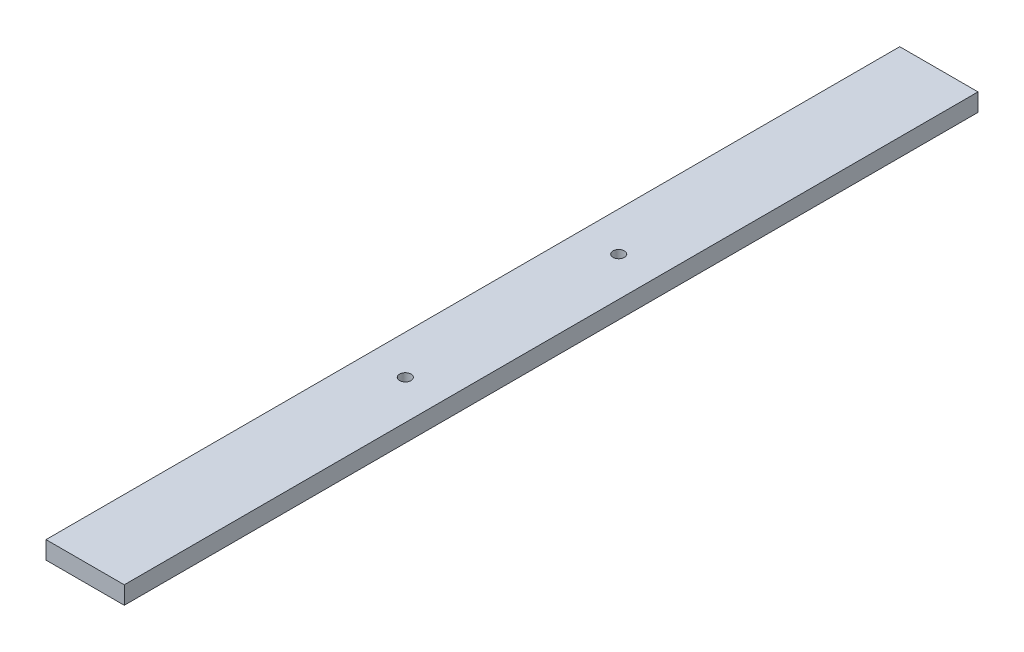
from build123d import *

# Parameters (mm, degrees)
SKETCH1_W           = 22
SKETCH1_H           = 5
BOSS_EXTRUDE1_DEPTH = 240
SKETCH2_R           = 1.6
CUT_EXTRUDE1_DEPTH  = 6


with BuildPart() as part:
    # Sketch1 → Boss-Extrude1 (new body)
    with BuildSketch(Plane.XY):
        Rectangle(SKETCH1_W, SKETCH1_H)
    extrude(amount=-BOSS_EXTRUDE1_DEPTH)

    # Sketch2 → Cut-Extrude1 (cut, through all)
    with BuildSketch(Plane(origin=(0, 2.5, 0), x_dir=(1, 0, 0), z_dir=(0, 1, 0))):
        with Locations((0, 150)):
            Circle(SKETCH2_R)
        with Locations((0, 90)):
            Circle(SKETCH2_R)
    extrude(amount=-CUT_EXTRUDE1_DEPTH, mode=Mode.SUBTRACT)


solid = part.part
